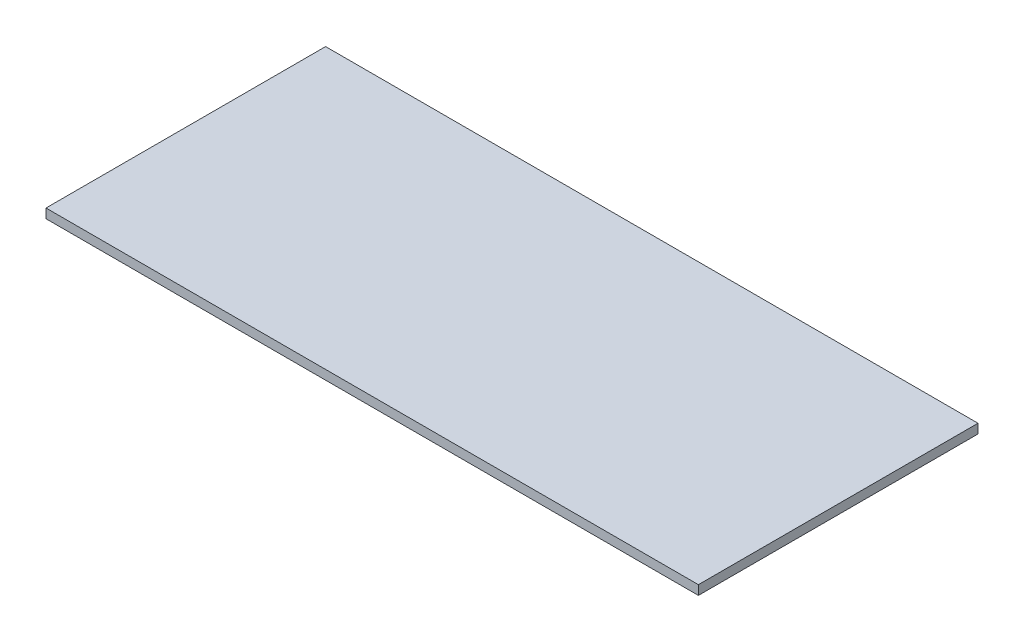
from build123d import *

# Parameters (mm, degrees)
SKETCH1_W           = 350
SKETCH1_H           = 150
BOSS_EXTRUDE1_DEPTH = 5


with BuildPart() as part:
    # Sketch1 → Boss-Extrude1 (new body)
    with BuildSketch(Plane(origin=(0, 0, 0), x_dir=(1, 0, 0), z_dir=(0, 1, 0))):
        Rectangle(SKETCH1_W, SKETCH1_H)
    extrude(amount=BOSS_EXTRUDE1_DEPTH)


solid = part.part
